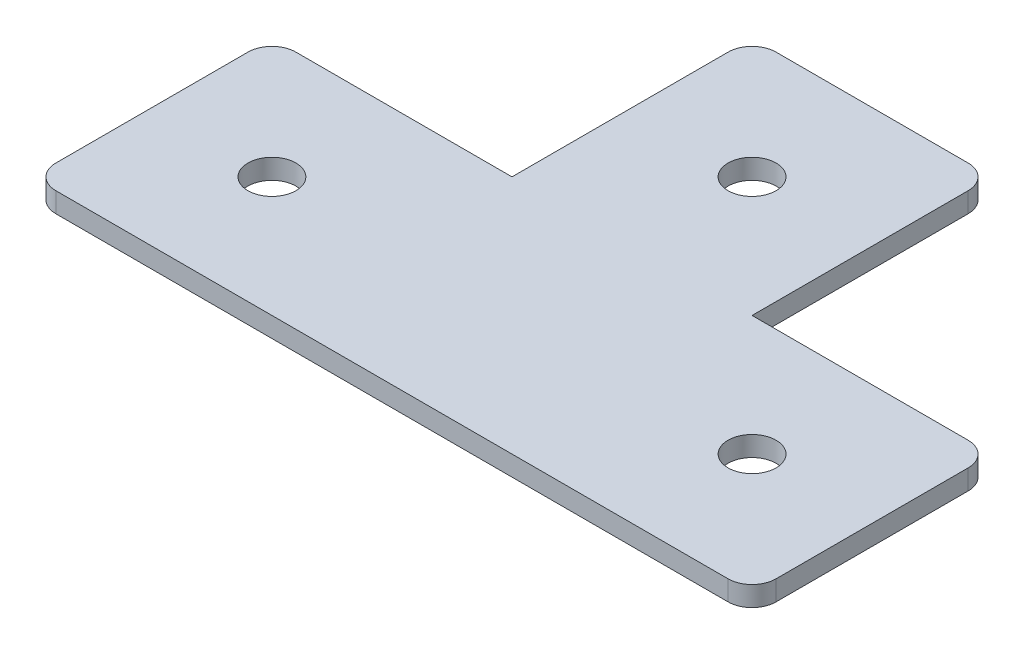
from build123d import *

# Parameters (mm, degrees)
BOSS_EXTRUDE1_DEPTH = 2.5
FILLET1_R           = 3
FILLET2_R           = 3
FILLET4_R           = 3
FILLET5_R           = 3
SKETCH2_R           = 3
CUT_EXTRUDE1_DEPTH  = 3
FILLET6_R           = 3
FILLET7_R           = 3


with BuildPart() as part:
    # Sketch1 → Boss-Extrude1 (new body)
    with BuildSketch(Plane(origin=(0, 0, 0), x_dir=(1, 0, 0), z_dir=(0, 1, 0))):
        Polygon((-12.469879518, 24.84939759), (17.530120482, 24.84939759), (17.530120482, -5.15060241), (47.530120482, -5.15060241), (47.530120482, -35.15060241), (17.530120482, -35.15060241), (-12.469879518, -35.15060241), (-42.469879518, -35.15060241), (-42.469879518, -5.15060241), (-12.469879518, -5.15060241), align=None)
    extrude(amount=BOSS_EXTRUDE1_DEPTH)

    # Fillet1
    fillet1_edges = [part.edges().sort_by_distance(p)[0] for p in [
        (-42.469879518, 1.25, 5.15060241),
    ]]
    fillet(fillet1_edges, radius=FILLET1_R)

    # Fillet2
    fillet2_edges = [part.edges().sort_by_distance(p)[0] for p in [
        (-42.469879518, 1.25, 35.15060241),
    ]]
    fillet(fillet2_edges, radius=FILLET2_R)

    # Fillet4
    fillet4_edges = [part.edges().sort_by_distance(p)[0] for p in [
        (17.530120482, 1.25, -24.84939759),
    ]]
    fillet(fillet4_edges, radius=FILLET4_R)

    # Fillet5
    fillet5_edges = [part.edges().sort_by_distance(p)[0] for p in [
        (-12.469879518, 1.25, -24.84939759),
    ]]
    fillet(fillet5_edges, radius=FILLET5_R)

    # Sketch2 → Cut-Extrude1 (cut)
    with BuildSketch(Plane(origin=(0, 2.5, 0), x_dir=(1, 0, 0), z_dir=(0, 1, 0))):
        with Locations((2.530120482, 9.84939759)):
            Circle(SKETCH2_R)
        with Locations((-27.469879518, -20.15060241)):
            Circle(SKETCH2_R)
        with Locations((32.530120482, -20.15060241)):
            Circle(SKETCH2_R)
    extrude(amount=-CUT_EXTRUDE1_DEPTH, mode=Mode.SUBTRACT)

    # Fillet6
    fillet6_edges = [part.edges().sort_by_distance(p)[0] for p in [
        (47.530120482, 1.25, 35.15060241),
    ]]
    fillet(fillet6_edges, radius=FILLET6_R)

    # Fillet7
    fillet7_edges = [part.edges().sort_by_distance(p)[0] for p in [
        (47.530120482, 1.25, 5.15060241),
    ]]
    fillet(fillet7_edges, radius=FILLET7_R)


solid = part.part
